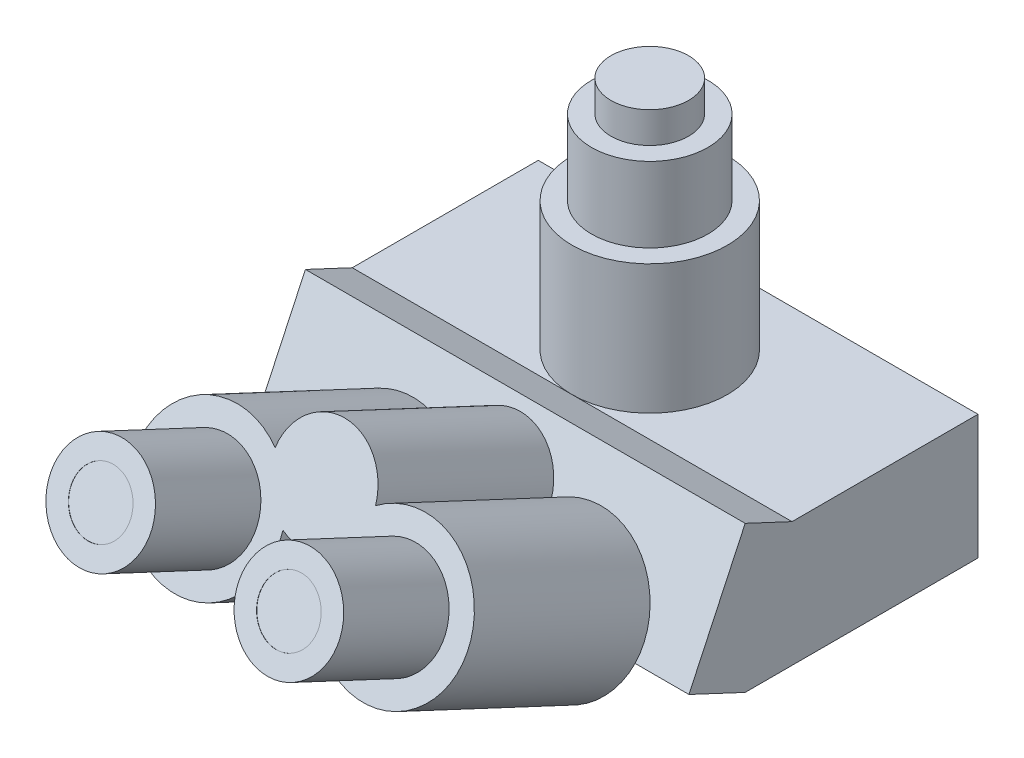
from build123d import *

# Parameters (mm, degrees)
BOSS_EXTRUDE1_DEPTH = 85
SKETCH4_R           = 30
BOSS_EXTRUDE2_DEPTH = 50
SKETCH5_R           = 22.5
BOSS_EXTRUDE3_DEPTH = 29
SKETCH6_R           = 15
BOSS_EXTRUDE4_DEPTH = 12
BOSS_EXTRUDE5_DEPTH = 75
SKETCH8_R           = 19.5
BOSS_EXTRUDE6_DEPTH = 45
SKETCH9_R           = 11.5
CUT_EXTRUDE1_DEPTH  = 0.1


with BuildPart() as part:
    # Sketch3 → Boss-Extrude1 (new, symmetric)
    with BuildSketch(Plane(origin=(0, 0, 0), x_dir=(0, 0, -1), z_dir=(1, 0, 0))):
        Polygon((0, 0), (90, 0), (90, 48.125), (18.113318582, 48.125), (0, 56.604840209), (-21.735982298, 10.17580825), align=None)
    extrude(amount=BOSS_EXTRUDE1_DEPTH, both=True)

    # Sketch4 → Boss-Extrude2 (add)
    with BuildSketch(Plane(origin=(0, 48.125, 0), x_dir=(1, 0, 0), z_dir=(0, 1, 0))):
        with Locations((0, 48.113318582)):
            Circle(SKETCH4_R)
    extrude(amount=BOSS_EXTRUDE2_DEPTH)

    # Sketch5 → Boss-Extrude3 (add)
    with BuildSketch(Plane(origin=(0, 98.125, 0), x_dir=(1, 0, 0), z_dir=(0, 1, 0))):
        with Locations((0, 48.113318582)):
            Circle(SKETCH5_R)
    extrude(amount=BOSS_EXTRUDE3_DEPTH)

    # Sketch6 → Boss-Extrude4 (add)
    with BuildSketch(Plane(origin=(0, 127.125, 0), x_dir=(1, 0, 0), z_dir=(0, 1, 0))):
        with Locations((0, 48.113318582)):
            Circle(SKETCH6_R)
    extrude(amount=BOSS_EXTRUDE4_DEPTH)

    # Sketch7 → Boss-Extrude5 (add)
    with BuildSketch(Plane(origin=(0, 10.17580825, 21.735982298), x_dir=(1, 0, 0), z_dir=(0, 0.4239920104282593, 0.9056659290781578))):
        with BuildLine():
            ThreePointArc((-8.058161684, 9.507934936), (0, 7.765075198), (8.058161684, 9.507934936))
            ThreePointArc((8.058161684, 9.507934936), (61.054790967, -7.984924802), (19.407215407, 29.165072602))
            ThreePointArc((19.407215407, 29.165072602), (0, 46.765075198), (-19.407215407, 29.165072602))
            ThreePointArc((-19.407215407, 29.165072602), (-61.054790967, -7.984924802), (-8.058161684, 9.507934936))
        make_face()
    extrude(amount=BOSS_EXTRUDE5_DEPTH)

    # Sketch8 → Boss-Extrude6 (add)
    with BuildSketch(Plane(origin=(0, 41.975209032, 89.660926979), x_dir=(1, 0, 0), z_dir=(0, 0.42399201042825935, 0.905665929078158))):
        with Locations((-36.373066959, 6.265075198)):
            Circle(SKETCH8_R)
        with Locations((36.373066959, 6.265075198)):
            Circle(SKETCH8_R)
    extrude(amount=BOSS_EXTRUDE6_DEPTH)

    # Sketch9 → Cut-Extrude1 (cut)
    with BuildSketch(Plane(origin=(0, 61.054849502, 130.415893787), x_dir=(1, 0, 0), z_dir=(0, 0.42399201042825946, 0.9056659290781579))):
        with Locations((-36.373066959, 6.265075198)):
            Circle(SKETCH9_R)
        with Locations((36.373066959, 6.265075198)):
            Circle(SKETCH9_R)
    extrude(amount=-CUT_EXTRUDE1_DEPTH, mode=Mode.SUBTRACT)


solid = part.part
